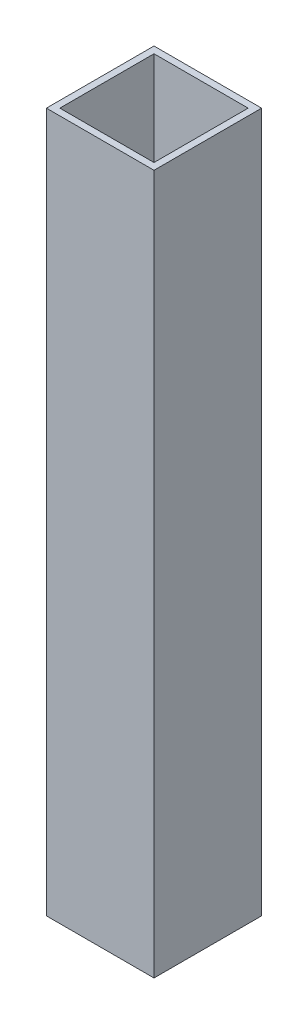
from build123d import *

# Parameters (mm, degrees)
SKETCH1_W           = 25.4
SKETCH1_H           = 25.4
SKETCH1_W_2         = 22.225
SKETCH1_H_2         = 22.225
EXTRUDE_THIN1_DEPTH = 165.1


with BuildPart() as part:
    # Sketch1 → Extrude-Thin1 (new body)
    with BuildSketch(Plane(origin=(0, 0, 0), x_dir=(1, 0, 0), z_dir=(0, 1, 0))):
        Rectangle(SKETCH1_W, SKETCH1_H)
        Rectangle(SKETCH1_W_2, SKETCH1_H_2, mode=Mode.SUBTRACT)
    extrude(amount=EXTRUDE_THIN1_DEPTH)


solid = part.part
